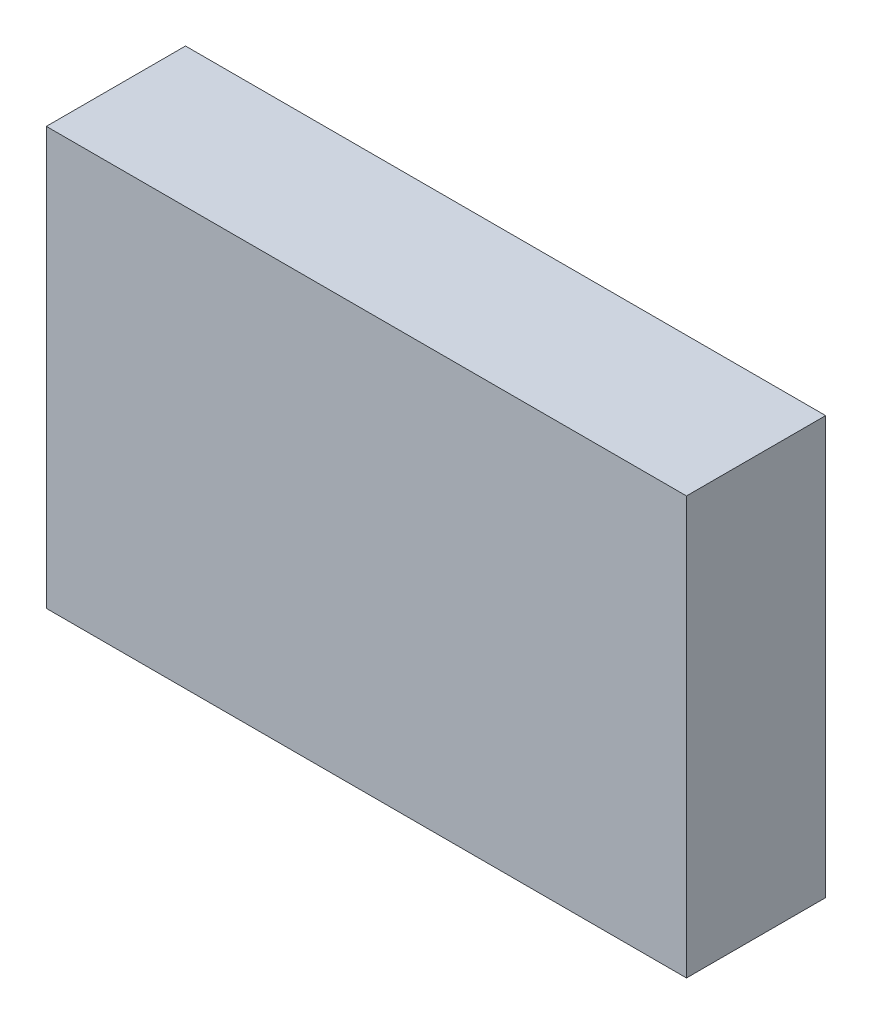
from build123d import *

# Parameters (mm, degrees)
ESQUISSE1_W        = 92
ESQUISSE1_H        = 60
BOSS_EXTRU_1_DEPTH = 20


with BuildPart() as part:
    # Esquisse1 → Boss.-Extru.1 (new body)
    with BuildSketch(Plane.XY):
        Rectangle(ESQUISSE1_W, ESQUISSE1_H)
    extrude(amount=BOSS_EXTRU_1_DEPTH)


solid = part.part
